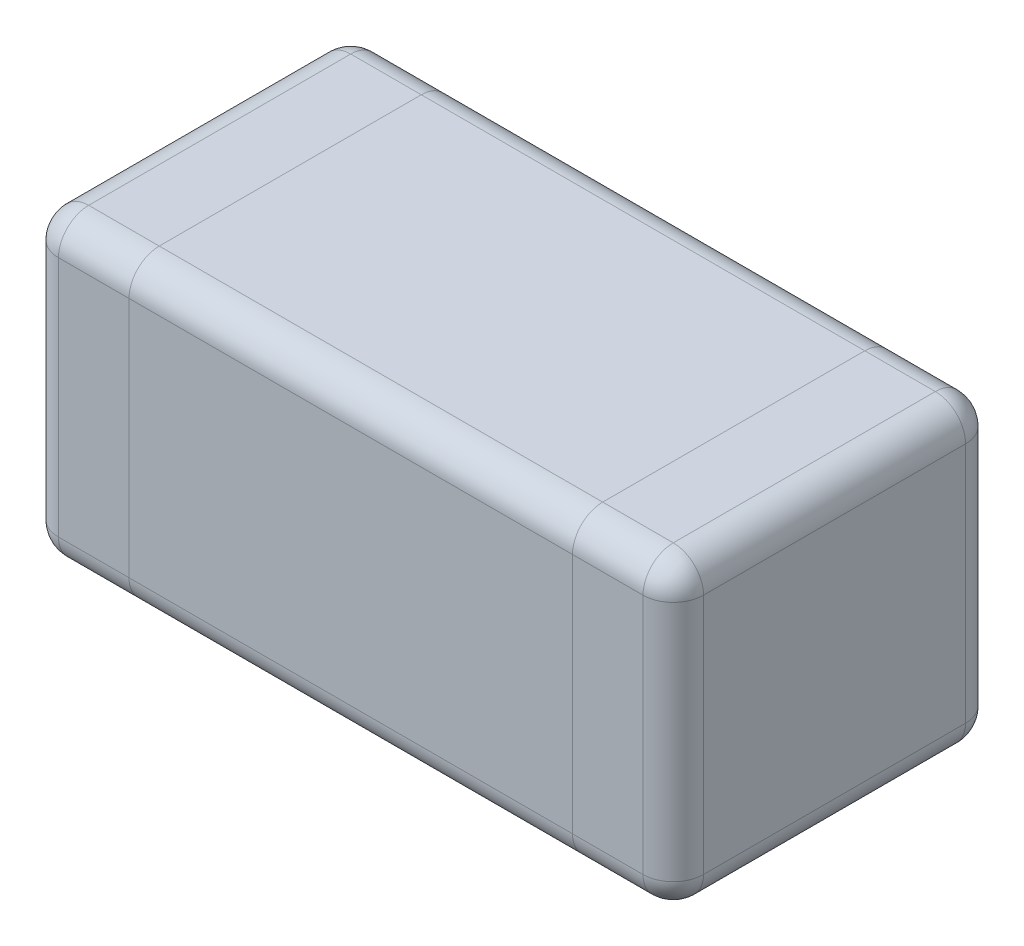
from build123d import *

# Parameters (mm, degrees)
SKETCH1_W           = 2.2
SKETCH1_H           = 1.6
BOSS_EXTRUDE1_DEPTH = 1.5
FILLET1_R           = 0.15
BOSS_EXTRUDE2_DEPTH = 0.5
FILLET2_R           = 0.15


with BuildPart() as part:
    # Sketch1 → Boss-Extrude1 (new body)
    with BuildSketch(Plane(origin=(0, 0, 0), x_dir=(1, 0, 0), z_dir=(0, 1, 0))):
        Rectangle(SKETCH1_W, SKETCH1_H)
    extrude(amount=BOSS_EXTRUDE1_DEPTH)

    # Fillet1
    fillet1_edges = [part.edges().sort_by_distance(p)[0] for p in [
        (0, 1.5, -0.8),
        (0, 0, -0.8),
        (0, 0, 0.8),
        (0, 1.5, 0.8),
    ]]
    fillet(fillet1_edges, radius=FILLET1_R)


with BuildPart() as body_2:
    # Sketch2 → Boss-Extrude2 (new body)
    with BuildSketch(Plane(origin=(1.1, 0, 0), x_dir=(0, 0, -1), z_dir=(1, 0, 0))):
        with BuildLine():
            Line((-0.8, 1.35), (-0.8, 0.15))
            ThreePointArc((-0.8, 0.15), (-0.756066017, 0.043933983), (-0.65, 0))
            Line((-0.65, 0), (0.65, 0))
            ThreePointArc((0.65, 0), (0.756066017, 0.043933983), (0.8, 0.15))
            Line((0.8, 0.15), (0.8, 1.35))
            ThreePointArc((0.8, 1.35), (0.756066017, 1.456066017), (0.65, 1.5))
            Line((0.65, 1.5), (-0.65, 1.5))
            ThreePointArc((-0.65, 1.5), (-0.756066017, 1.456066017), (-0.8, 1.35))
        make_face()
    extrude(amount=BOSS_EXTRUDE2_DEPTH)

    # Fillet2
    fillet2_edges = [body_2.edges().sort_by_distance(p)[0] for p in [
        (1.6, 0.043933983, 0.756066017),
        (1.6, 0, 0),
        (1.6, 0.043933983, -0.756066017),
        (1.6, 0.75, -0.8),
        (1.6, 1.456066017, -0.756066017),
        (1.6, 1.5, 0),
        (1.6, 1.456066017, 0.756066017),
        (1.6, 0.75, 0.8),
    ]]
    fillet(fillet2_edges, radius=FILLET2_R)


with BuildPart() as body_3:
    # Mirror1: mirrored copy
    add(body_2.part.mirror(Plane(origin=(0, 0, 0), x_dir=(0, 0, 1), z_dir=(1, 0, 0))))


solid = Compound([part.part, body_2.part, body_3.part])
